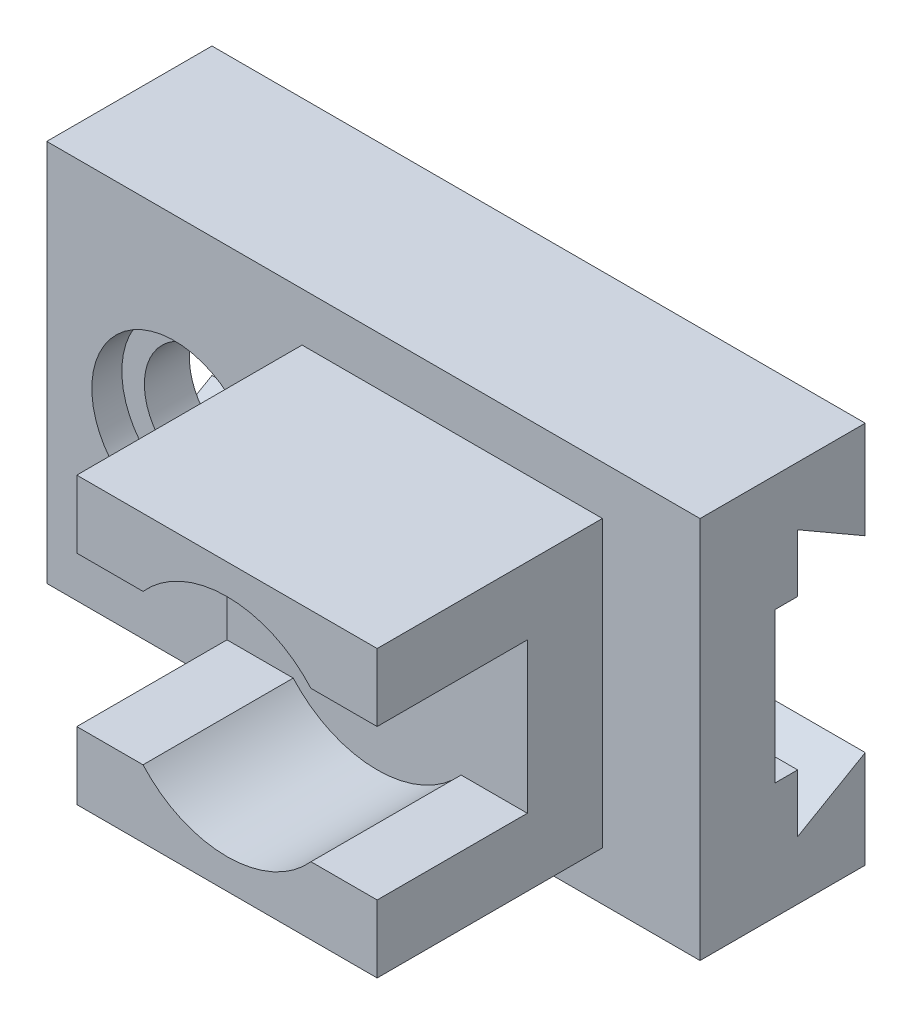
from build123d import *

# Parameters (mm, degrees)
SKETCH1_W         = 87
SKETCH1_H         = 50.982
BASE_YELLOW_DEPTH = 22
SKETCH2_R         = 11
COUNTERBOR_DEPTH  = 4
SKETCH2_5_R       = 8
COUNTERBOR2_DEPTH = 56.009463559
SKETCH5_W         = 40
SKETCH5_H         = 38
BASE_RED_DEPTH    = 30
BASE_PURPLE_DEPTH = 20
BASE_TURKIZ_DEPTH = 96.492361375


with BuildPart() as part:
    # Sketch1 → base-yellow (new body)
    with BuildSketch(Plane.XY):
        Rectangle(SKETCH1_W, SKETCH1_H)
    extrude(amount=-BASE_YELLOW_DEPTH)

    # Sketch2 → counterbor (cut)
    with BuildSketch(Plane.XY):
        with Locations((-26.5, 0)):
            Circle(SKETCH2_R)
    extrude(amount=-COUNTERBOR_DEPTH, mode=Mode.SUBTRACT)

    # Sketch2_5 → counterbor2 (cut, through all)
    with BuildSketch(Plane.XY):
        with Locations((-26.5, 0)):
            Circle(SKETCH2_5_R)
    extrude(amount=-COUNTERBOR2_DEPTH, mode=Mode.SUBTRACT)

    # Sketch5 → base-red (add)
    with BuildSketch(Plane.XY):
        with Locations((10.5, 0)):
            Rectangle(SKETCH5_W, SKETCH5_H)
    extrude(amount=BASE_RED_DEPTH)

    # Sketch7 → base-purple (cut)
    with BuildSketch(Plane.XY.offset(30)):
        with BuildLine():
            Line((-9.5, 10), (-9.5, -10))
            Line((-9.5, -10), (-0.680339887, -10))
            ThreePointArc((-0.680339887, -10), (10.5, -15), (21.680339887, -10))
            Line((21.680339887, -10), (30.5, -10))
            Line((30.5, -10), (30.5, 10))
            Line((30.5, 10), (21.680339887, 10))
            ThreePointArc((21.680339887, 10), (10.5, 15), (-0.680339887, 10))
            Line((-0.680339887, 10), (-9.5, 10))
        make_face()
    extrude(amount=-BASE_PURPLE_DEPTH, mode=Mode.SUBTRACT)

    # Sketch8 → base-turkiz (cut, through all)
    with BuildSketch(Plane.ZY.offset(43.5)):
        Polygon((-10, 10), (-10, -10), (-13, -10), (-13, -17.696152423), (-22, -12.5), (-22, 12.5), (-13, 17.696152423), (-13, 10), align=None)
    extrude(amount=-BASE_TURKIZ_DEPTH, mode=Mode.SUBTRACT)


solid = part.part
